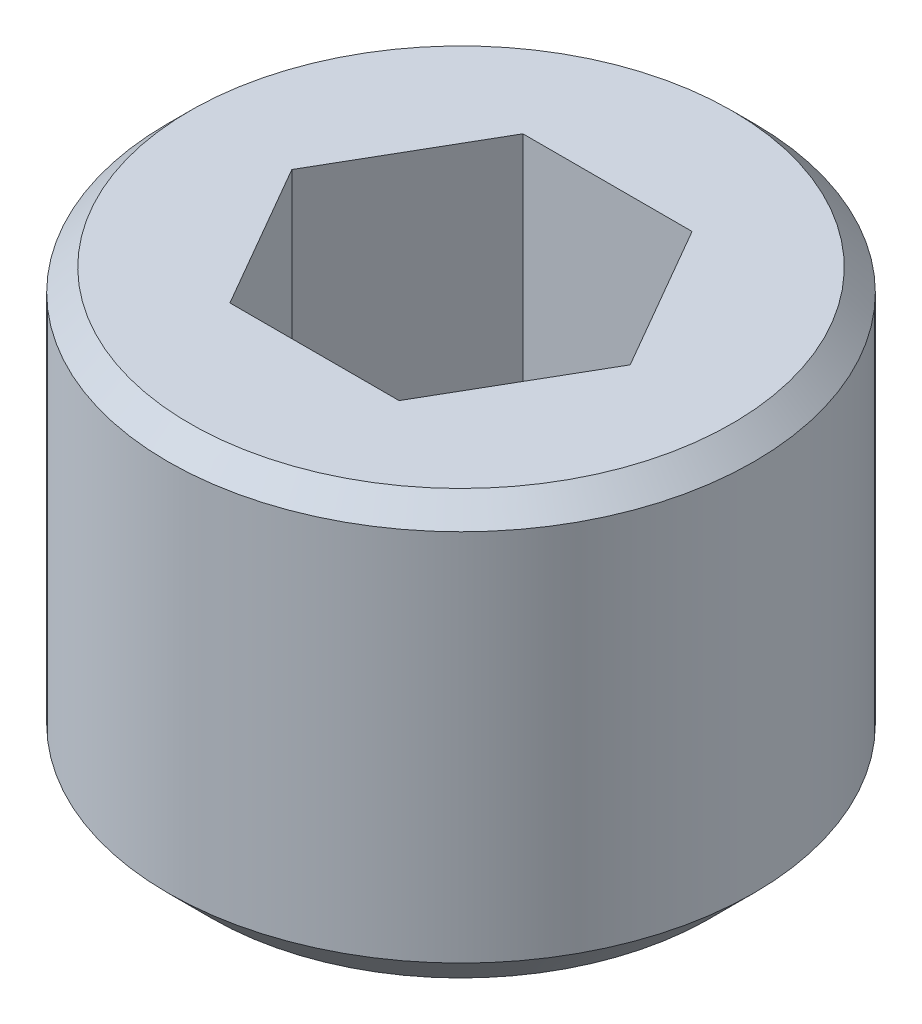
from build123d import *

# Parameters (mm, degrees)
CROQUIS1_W            = 2
CROQUIS1_H            = 3
CORTAR_EXTRUIR2_DEPTH = 2
CHAFL_N3_SIZE         = 0.3
CHAFL_N4_SIZE         = 0.15


with BuildPart() as part:
    # Croquis1 → Revolución1 (revolve)
    with BuildSketch(Plane.XY):
        with Locations((1, -1.5)):
            Rectangle(CROQUIS1_W, CROQUIS1_H)
    revolve(axis=Axis((0, 0, 0), (0, -1, 0)))

    # Croquis3 → Cortar-Extruir2 (cut)
    with BuildSketch(Plane(origin=(0, 0, 0), x_dir=(1, 0, 0), z_dir=(0, 1, 0))):
        Polygon((-0.577350269, 1), (-1.154700538, 0), (-0.577350269, -1), (0.577350269, -1), (1.154700538, 0), (0.577350269, 1), align=None)
    extrude(amount=-CORTAR_EXTRUIR2_DEPTH, mode=Mode.SUBTRACT)

    # Chaflán3
    chafl_n3_edges = [part.edges().sort_by_distance(p)[0] for p in [
        (-2, -3, 0),
    ]]
    chamfer(chafl_n3_edges, length=CHAFL_N3_SIZE)

    # Chaflán4
    chafl_n4_edges = [part.edges().sort_by_distance(p)[0] for p in [
        (-2, 0, 0),
    ]]
    chamfer(chafl_n4_edges, length=CHAFL_N4_SIZE)


solid = part.part
